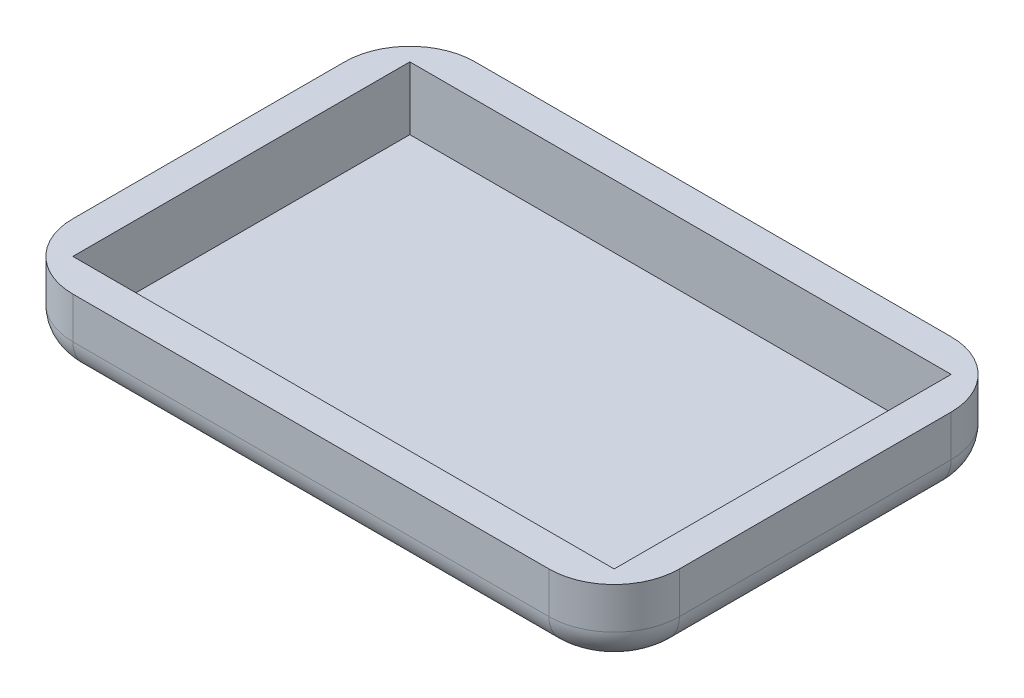
from build123d import *

# Parameters (mm, degrees)
SKETCH1_W           = 70.866
SKETCH1_H           = 46.99
BOSS_EXTRUDE1_DEPTH = 8.636
SKETCH2_W           = 63.246
SKETCH2_H           = 39.37
CUT_EXTRUDE1_DEPTH  = 7.366
FILLET2_R           = 7.62
FILLET3_R           = 3.81


with BuildPart() as part:
    # Sketch1 → Boss-Extrude1 (new body)
    with BuildSketch(Plane(origin=(0, 0, 0), x_dir=(1, 0, 0), z_dir=(0, 1, 0))):
        with Locations((35.433, 23.495)):
            Rectangle(SKETCH1_W, SKETCH1_H)
    extrude(amount=BOSS_EXTRUDE1_DEPTH)

    # Sketch2 → Cut-Extrude1 (cut)
    with BuildSketch(Plane(origin=(0, 8.636, 0), x_dir=(1, 0, 0), z_dir=(0, 1, 0))):
        with Locations((35.433, 23.495)):
            Rectangle(SKETCH2_W, SKETCH2_H)
    extrude(amount=-CUT_EXTRUDE1_DEPTH, mode=Mode.SUBTRACT)

    # Fillet2
    fillet2_edges = [part.edges().sort_by_distance(p)[0] for p in [
        (0, 4.318, -46.99),
        (70.866, 4.318, -46.99),
        (70.866, 4.318, 0),
        (0, 4.318, 0),
    ]]
    fillet(fillet2_edges, radius=FILLET2_R)

    # Fillet3
    fillet3_edges = [part.edges().sort_by_distance(p)[0] for p in [
        (35.433, 0, -46.99),
        (0, 0, -23.495),
        (70.866, 0, -23.495),
        (35.433, 0, 0),
        (2.231846327, 0, -44.758153673),
        (2.231846327, 0, -2.231846327),
        (68.634153673, 0, -2.231846327),
        (68.634153673, 0, -44.758153673),
    ]]
    fillet(fillet3_edges, radius=FILLET3_R)


solid = part.part
